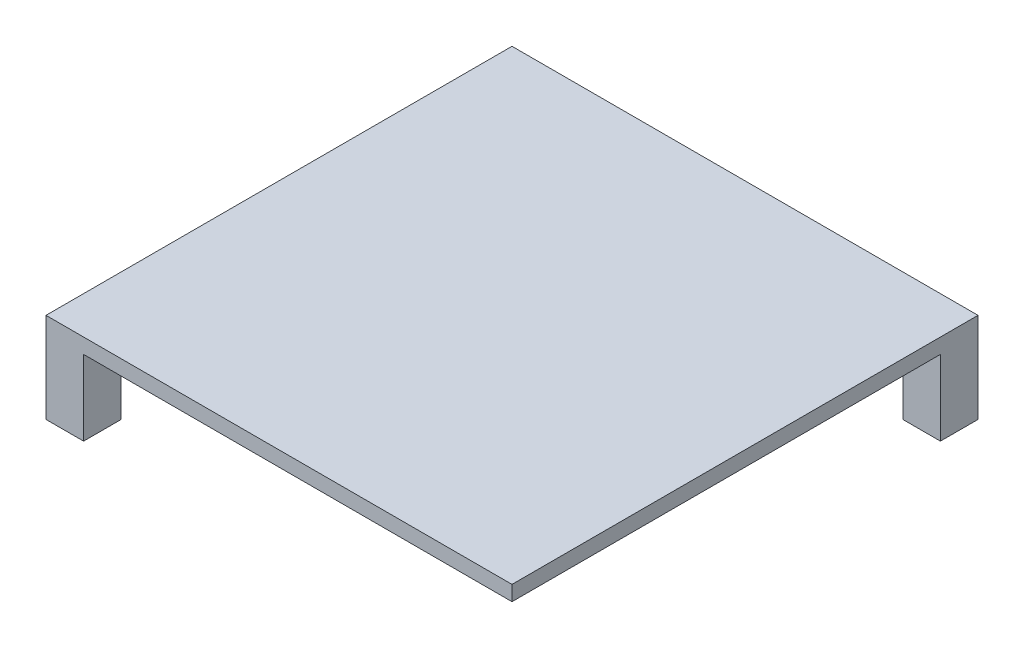
from build123d import *

# Parameters (mm, degrees)
SKETCH2_W           = 62
SKETCH2_H           = 62
BOSS_EXTRUDE1_DEPTH = 2
SKETCH3_W           = 5
SKETCH3_H           = 5
BOSS_EXTRUDE2_DEPTH = 10
SKETCH6_R           = 1
CUT_EXTRUDE2_DEPTH  = 3
CIRPATTERN1_COUNT   = 3
CIRPATTERN1_ANGLE   = 180


with BuildPart() as part:
    # Sketch2 → Boss-Extrude1 (new body)
    with BuildSketch(Plane(origin=(0, 0, 0), x_dir=(1, 0, 0), z_dir=(0, 1, 0))):
        Rectangle(SKETCH2_W, SKETCH2_H)
    extrude(amount=BOSS_EXTRUDE1_DEPTH)

    # Sketch3 → Boss-Extrude2 (add)
    with BuildSketch(Plane.XZ):
        with Locations((-28.5, 28.5)):
            Rectangle(SKETCH3_W, SKETCH3_H)
    boss_extrude2 = extrude(amount=BOSS_EXTRUDE2_DEPTH)

    # Sketch6 → Cut-Extrude2 (cut)
    with BuildSketch(Plane.XZ.offset(10)):
        with Locations((-28.5, 28.5)):
            Circle(SKETCH6_R)
    cut_extrude2 = extrude(amount=-CUT_EXTRUDE2_DEPTH, mode=Mode.SUBTRACT)

    # CirPattern1: Boss-Extrude2, Cut-Extrude2 ×3 about axis
    cirpattern1_axis = Axis((0, 0, 0), (0, -1, 0))
    for i in range(1, CIRPATTERN1_COUNT):
        add(boss_extrude2.rotate(cirpattern1_axis, i * CIRPATTERN1_ANGLE / (CIRPATTERN1_COUNT - 1)))
        add(cut_extrude2.rotate(cirpattern1_axis, i * CIRPATTERN1_ANGLE / (CIRPATTERN1_COUNT - 1)), mode=Mode.SUBTRACT)


solid = part.part
